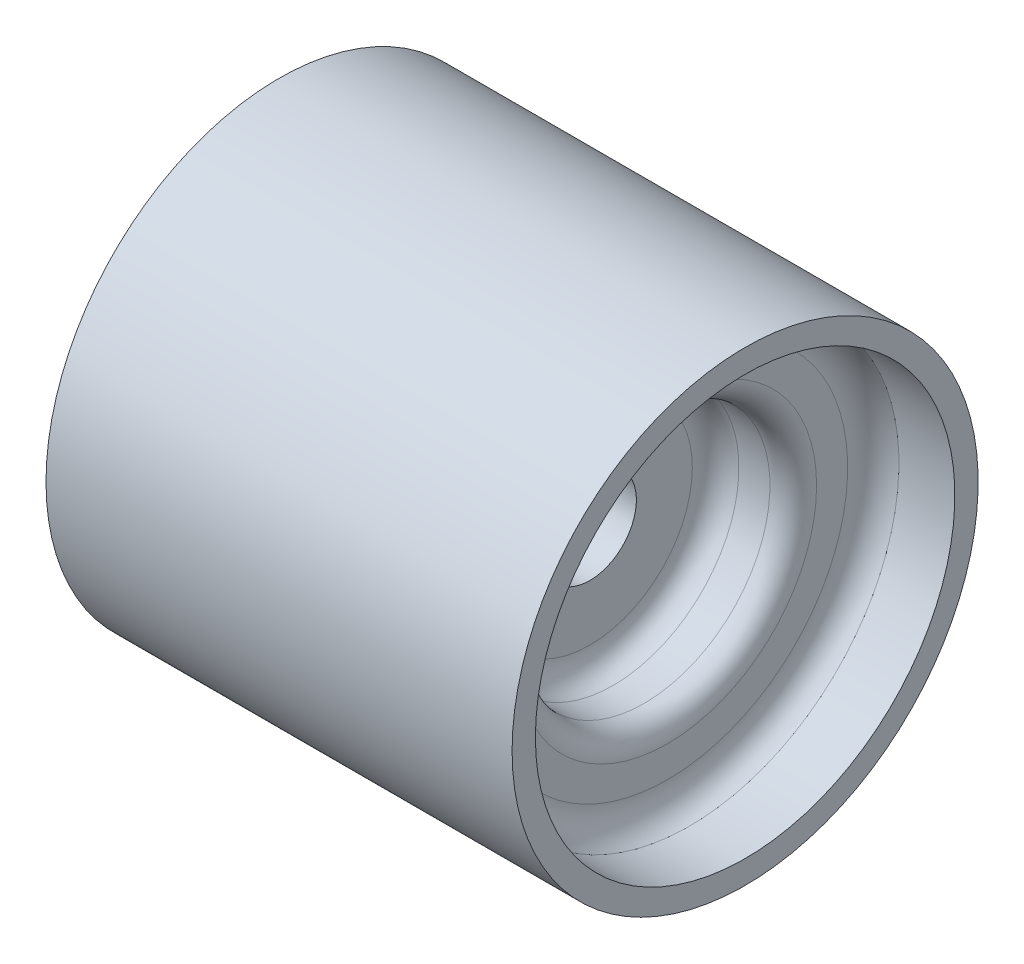
from build123d import *


with BuildPart() as part:
    # Sketch1 → Revolve1 (revolve)
    with BuildSketch(Plane.XY):
        with BuildLine():
            Line((-42.333333333, 63.5), (84.666666667, 63.5))
            Line((84.666666667, 63.5), (84.666666667, 57.15))
            Line((84.666666667, 57.15), (69.426666667, 57.15))
            ThreePointArc((69.426666667, 57.15), (64.961150677, 54.235204762), (63.499999992, 49.106666667))
            Line((63.499999992, 49.106666667), (63.499999992, 40.64))
            ThreePointArc((63.499999992, 40.64), (61.640128052, 36.149871939), (57.149999992, 34.29))
            Line((57.149999992, 34.29), (48.683333333, 34.29))
            ThreePointArc((48.683333333, 34.29), (44.193205273, 32.430128061), (42.333333333, 27.94))
            Line((42.333333333, 27.94), (42.333333333, 12.7))
            Line((42.333333333, 12.7), (0, 12.7))
            Line((0, 12.7), (0, 27.855333333))
            ThreePointArc((0, 27.855333333), (-1.859871939, 32.345461394), (-6.35, 34.205333333))
            Line((-6.35, 34.205333333), (-14.732, 34.205333333))
            ThreePointArc((-14.732, 34.205333333), (-19.151185851, 36.136147482), (-21.082, 40.555333333))
            Line((-21.082, 40.555333333), (-21.082, 49.022))
            ThreePointArc((-21.082, 49.022), (-22.545694215, 54.226417126), (-27.093333333, 57.15))
            Line((-27.093333333, 57.15), (-42.333333333, 57.15))
            Line((-42.333333333, 57.15), (-42.333333333, 63.5))
        make_face()
    revolve(axis=Axis((0, 0, 0), (1, 0, 0)))


solid = part.part
